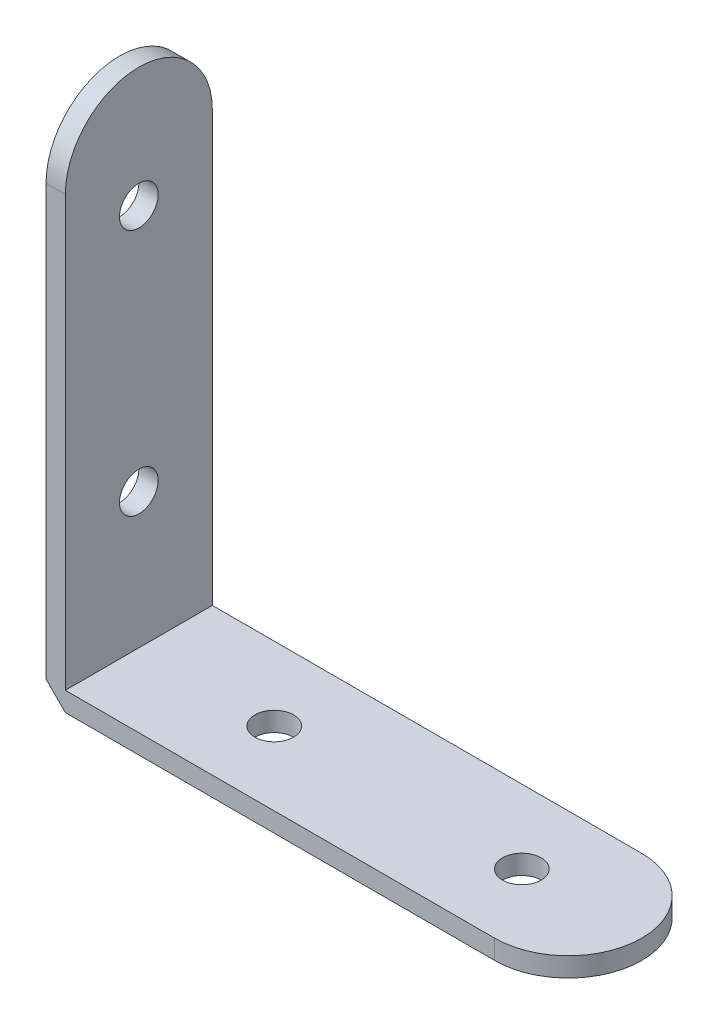
from build123d import *

# Parameters (mm, degrees)
SKETCH_1_R          = 2.5
EXTRUDE_1_DEPTH     = 2.5
EXTRUDE_2_DEPTH     = 19
CUT_EXTRUDE_1_DEPTH = 19
SKETCH_4_R          = 2.5
CUT_EXTRUDE_2_DEPTH = 19


with BuildPart() as part:
    # 草图1 → 凸台-拉伸1 (new body)
    with BuildSketch(Plane(origin=(0, 0, 0), x_dir=(1, 0, 0), z_dir=(0, 1, 0))):
        with BuildLine():
            Line((23, -9.5), (-32.5, -9.5))
            Line((-32.5, -9.5), (-32.5, 9.5))
            Line((-32.5, 9.5), (23, 9.5))
            ThreePointArc((23, 9.5), (32.5, 0), (23, -9.5))
        make_face()
        with Locations((-15, 0)):
            Circle(SKETCH_1_R, mode=Mode.SUBTRACT)
        with Locations((17, 0)):
            Circle(SKETCH_1_R, mode=Mode.SUBTRACT)
    extrude(amount=EXTRUDE_1_DEPTH)

    # 草图2 → 凸台-拉伸2 (add)
    with BuildSketch(Plane.XY.offset(9.5)):
        Polygon((-35, 2.5), (-32.5, 0), (-32.5, 2.5), (-32.5, 67.5), (-35, 67.5), align=None)
    extrude(amount=-EXTRUDE_2_DEPTH)

    # 草图3 → 切除-拉伸1 (cut)
    with BuildSketch(Plane(origin=(-32.5, 0, 0), x_dir=(0, 0, -1), z_dir=(1, 0, 0))):
        with BuildLine():
            Line((9.5, 67.5), (0, 67.5))
            ThreePointArc((0, 67.5), (6.717514421, 64.717514421), (9.5, 58))
            Line((9.5, 58), (9.5, 67.5))
        make_face()
        with BuildLine():
            Line((0, 67.5), (-9.5, 67.5))
            Line((-9.5, 67.5), (-9.5, 58))
            ThreePointArc((-9.5, 58), (-6.717514421, 64.717514421), (0, 67.5))
        make_face()
    extrude(amount=-CUT_EXTRUDE_1_DEPTH, mode=Mode.SUBTRACT)

    # 草图4 → 切除-拉伸2 (cut)
    with BuildSketch(Plane(origin=(-32.5, 0, 0), x_dir=(0, 0, -1), z_dir=(1, 0, 0))):
        with Locations((0, 52)):
            Circle(SKETCH_4_R)
        with Locations((0, 20)):
            Circle(SKETCH_4_R)
    extrude(amount=-CUT_EXTRUDE_2_DEPTH, mode=Mode.SUBTRACT)


solid = part.part
